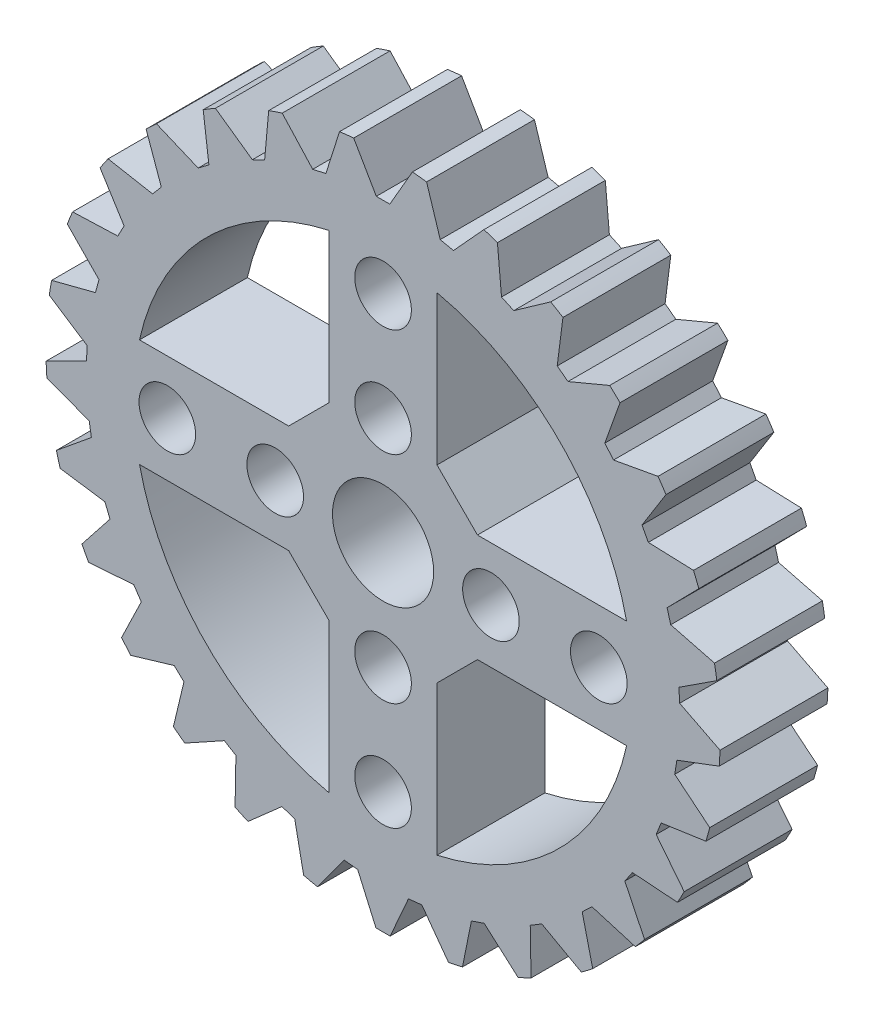
from build123d import *

# Parameters (mm, degrees)
SKETCH1_R           = 25
BOSS_EXTRUDE1_DEPTH = 8
CHAMFER1_SIZE       = 3
SKETCH2_R           = 3.75
SKETCH2_R_2         = 2.1
CUT_EXTRUDE1_DEPTH  = 10
CUT_EXTRUDE4_DEPTH  = 10
CIRPATTERN1_COUNT   = 29
CIRPATTERN2_COUNT   = 4


with BuildPart() as part:
    # Sketch1 → Boss-Extrude1 (new body)
    with BuildSketch(Plane.XY):
        Circle(SKETCH1_R)
        with BuildLine():
            Line((-4, 18.062391868), (-4, 4))
            Line((-4, 4), (-18.062391868, 4))
            ThreePointArc((-18.062391868, 4), (-13.081475452, 13.081475452), (-4, 18.062391868))
        make_face(mode=Mode.SUBTRACT)
        with BuildLine():
            Line((-18.062391868, -4), (-4, -4))
            Line((-4, -4), (-4, -18.062391868))
            ThreePointArc((-4, -18.062391868), (-13.081475452, -13.081475452), (-18.062391868, -4))
        make_face(mode=Mode.SUBTRACT)
        with BuildLine():
            Line((4, -18.062391868), (4, -4))
            Line((4, -4), (18.062391868, -4))
            ThreePointArc((18.062391868, -4), (13.081475452, -13.081475452), (4, -18.062391868))
        make_face(mode=Mode.SUBTRACT)
        with BuildLine():
            Line((18.062391868, 4), (4, 4))
            Line((4, 4), (4, 18.062391868))
            ThreePointArc((4, 18.062391868), (13.081475452, 13.081475452), (18.062391868, 4))
        make_face(mode=Mode.SUBTRACT)
    extrude(amount=BOSS_EXTRUDE1_DEPTH)

    # Chamfer1
    chamfer1_edges = [part.edges().sort_by_distance(p)[0] for p in [
        (-4, 4, 4),
        (4, 4, 4),
        (-4, -4, 4),
        (4, -4, 4),
    ]]
    chamfer(chamfer1_edges, length=CHAMFER1_SIZE)

    # Sketch2 → Cut-Extrude1 (cut)
    with BuildSketch(Plane.XY.offset(8)):
        Circle(SKETCH2_R)
        with Locations((-8, 0)):
            Circle(SKETCH2_R_2)
        with Locations((-16, 0)):
            Circle(SKETCH2_R_2)
    cut_extrude1 = extrude(amount=-CUT_EXTRUDE1_DEPTH, mode=Mode.SUBTRACT)

    # Sketch3 → Cut-Extrude4 (cut)
    with BuildSketch(Plane.XY.offset(8)):
        Polygon((-2.809401077, 26), (-0.5, 22), (0.5, 22), (2.809401077, 26), align=None)
    cut_extrude4 = extrude(amount=-CUT_EXTRUDE4_DEPTH, mode=Mode.SUBTRACT)

    # CirPattern1: Cut-Extrude4 ×29 about axis
    cirpattern1_axis = Axis((0, 0, 0), (0, 0, 1))
    for i in range(1, CIRPATTERN1_COUNT):
        add(cut_extrude4.rotate(cirpattern1_axis, i * 360 / CIRPATTERN1_COUNT), mode=Mode.SUBTRACT)

    # CirPattern2: Cut-Extrude1 ×4 about axis
    cirpattern2_axis = Axis((0, 0, 0), (0, 0, 1))
    for i in range(1, CIRPATTERN2_COUNT):
        add(cut_extrude1.rotate(cirpattern2_axis, i * 360 / CIRPATTERN2_COUNT), mode=Mode.SUBTRACT)


solid = part.part
